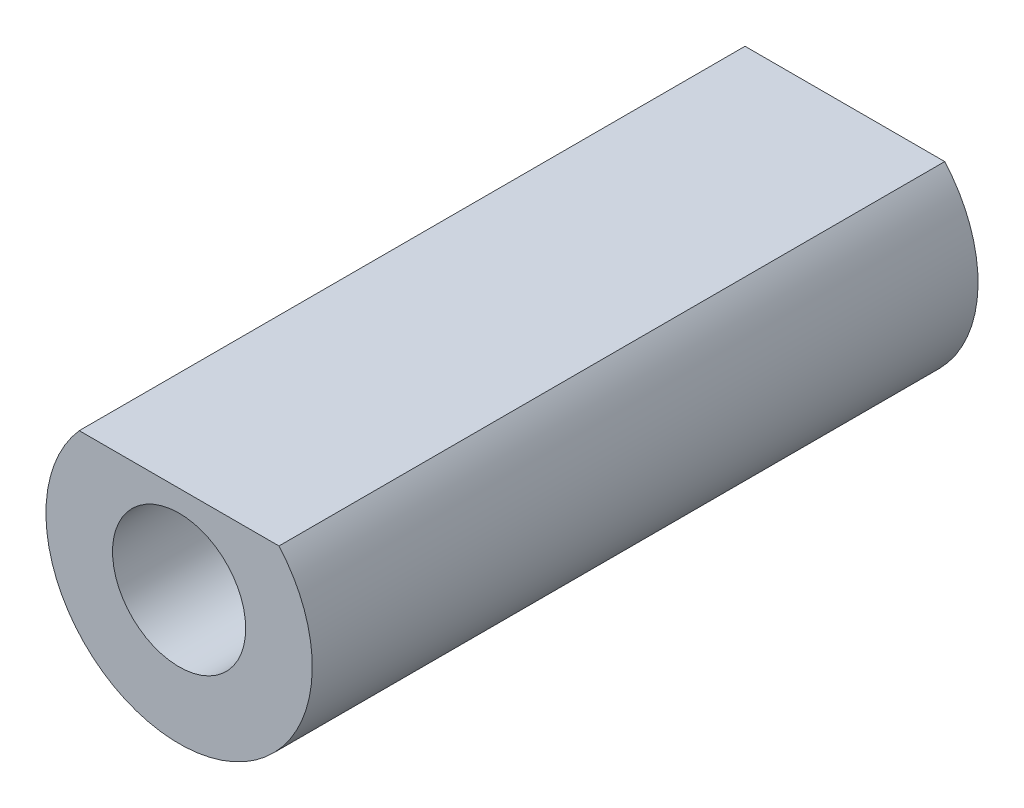
from build123d import *

# Parameters (mm, degrees)
ESBO_O1_W             = 1
ESBO_O1_H             = 10
CORTE_EXTRUS_O1_DEPTH = 11


with BuildPart() as part:
    # Esboço1 → Revolução1 (revolve)
    with BuildSketch(Plane(origin=(0, 0, 0), x_dir=(1, 0, 0), z_dir=(0, 1, 0))):
        with Locations((-1.5, 5)):
            Rectangle(ESBO_O1_W, ESBO_O1_H)
    revolve(axis=Axis((0, 0, 0), (0, 0, -1)))

    # Esboço2 → Corte-extrusão1 (cut, through all)
    with BuildSketch(Plane.XY):
        with BuildLine():
            Line((-1.5, 1.322875656), (1.5, 1.322875656))
            ThreePointArc((1.5, 1.322875656), (0, 2), (-1.5, 1.322875656))
        make_face()
    extrude(amount=-CORTE_EXTRUS_O1_DEPTH, mode=Mode.SUBTRACT)


solid = part.part
